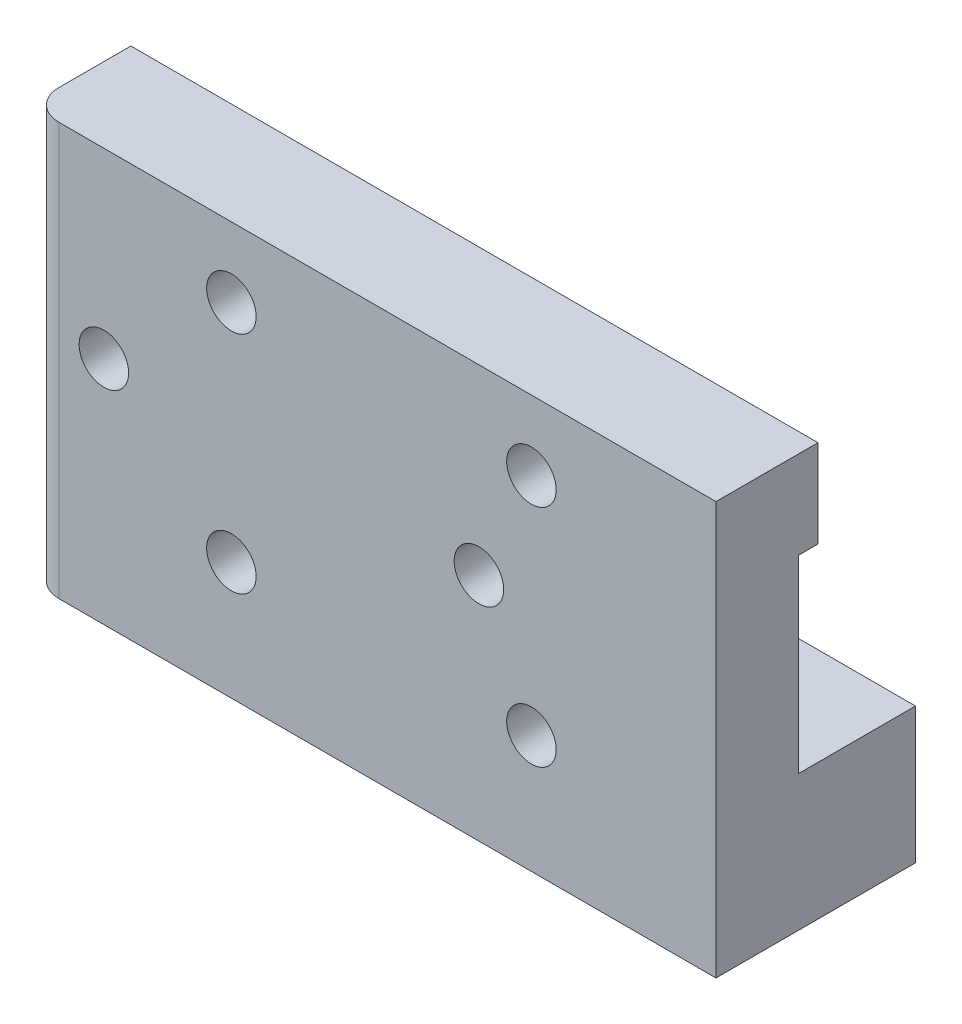
from build123d import *

# Parameters (mm, degrees)
SALIENTE_EXTRUIR1_START      = 0.1
SALIENTE_EXTRUIR1_DEPTH      = 1.3
SALIENTE_EXTRUIR3_START      = 0.1
SALIENTE_EXTRUIR3_DEPTH      = 1.3
SALIENTE_EXTRUIR3_DEPTH_BACK = 6.5
SALIENTE_EXTRUIR2_START      = 1.4
CROQUIS1_3_W                 = 45.8
CROQUIS1_3_H                 = 27.5
CROQUIS1_3_R                 = 1.65
SALIENTE_EXTRUIR2_DEPTH      = 5.5
REDONDEO2_R                  = 2


with BuildPart() as part:
    # Croquis1 → Saliente-Extruir1 (new body)
    with BuildSketch(Plane.XY.offset(SALIENTE_EXTRUIR1_START)):
        with BuildLine():
            Line((-13.85, -3.2), (-59.65, -3.2))
            Line((-59.65, -3.2), (-59.65, -9.05))
            Line((-59.65, -9.05), (-47.282475165, -9.05))
            ThreePointArc((-47.282475165, -9.05), (-46.803420224, -6.334895379), (-44.5, -7.85))
            ThreePointArc((-44.5, -7.85), (-44.634895379, -8.503420224), (-45.017524835, -9.05))
            Line((-45.017524835, -9.05), (-27.282475165, -9.05))
            ThreePointArc((-27.282475165, -9.05), (-26.803420224, -6.334895379), (-24.5, -7.85))
            ThreePointArc((-24.5, -7.85), (-24.634895379, -8.503420224), (-25.017524835, -9.05))
            Line((-25.017524835, -9.05), (-13.85, -9.05))
            Line((-13.85, -9.05), (-13.85, -3.2))
        make_face()
    extrude(amount=SALIENTE_EXTRUIR1_DEPTH)



with BuildPart() as body_2:
    # Croquis1_5 → Saliente-Extruir3 (new, two sides)
    with BuildSketch(Plane.XY.offset(SALIENTE_EXTRUIR3_START)) as saliente_extruir3_sk:
        with BuildLine():
            Line((-47.282489505, -21.65), (-59.65, -21.65))
            Line((-59.65, -21.65), (-59.65, -30.7))
            Line((-59.65, -30.7), (-13.85, -30.7))
            Line((-13.85, -30.7), (-13.85, -21.65))
            Line((-13.85, -21.65), (-25.017510495, -21.65))
            ThreePointArc((-25.017510495, -21.65), (-24.634891475, -22.196575296), (-24.5, -22.849986467))
            ThreePointArc((-24.5, -22.849986467), (-26.803411171, -24.365094992), (-27.282489505, -21.65))
            Line((-27.282489505, -21.65), (-45.017510495, -21.65))
            ThreePointArc((-45.017510495, -21.65), (-44.634891475, -22.196575296), (-44.5, -22.849986467))
            ThreePointArc((-44.5, -22.849986467), (-46.803411171, -24.365094992), (-47.282489505, -21.65))
        make_face()
    extrude(amount=SALIENTE_EXTRUIR3_DEPTH)
    extrude(saliente_extruir3_sk.sketch, amount=-SALIENTE_EXTRUIR3_DEPTH_BACK)


with BuildPart() as part_1:
    add(part.part)

    add(body_2.part)  # Saliente-Extruir2 merges body 2
    # Croquis1_3 → Saliente-Extruir2 (add)
    with BuildSketch(Plane.XY.offset(SALIENTE_EXTRUIR2_START)):
        with Locations((-36.75, -16.95)):
            Rectangle(CROQUIS1_3_W, CROQUIS1_3_H)
        with Locations(Location((-46.15, -22.849986467, 0), (0, 0, 133.342442907))):
            Circle(CROQUIS1_3_R, mode=Mode.SUBTRACT)
        with Locations(Location((-26.15, -22.849986467, 0), (0, 0, 133.342442907))):
            Circle(CROQUIS1_3_R, mode=Mode.SUBTRACT)
        with Locations(Location((-26.15, -7.85, 0), (0, 0, 226.658241773))):
            Circle(CROQUIS1_3_R, mode=Mode.SUBTRACT)
        with Locations(Location((-46.15, -7.85, 0), (0, 0, 226.658241773))):
            Circle(CROQUIS1_3_R, mode=Mode.SUBTRACT)
        with Locations((-54.65, -15.35)):
            Circle(CROQUIS1_3_R, mode=Mode.SUBTRACT)
        with Locations((-29.65, -15.35)):
            Circle(CROQUIS1_3_R, mode=Mode.SUBTRACT)
    extrude(amount=SALIENTE_EXTRUIR2_DEPTH)

    # Redondeo2
    redondeo2_edges = [part_1.edges().sort_by_distance(p)[0] for p in [
        (-59.65, -16.95, 6.9),
    ]]
    fillet(redondeo2_edges, radius=REDONDEO2_R)


solid = part_1.part
